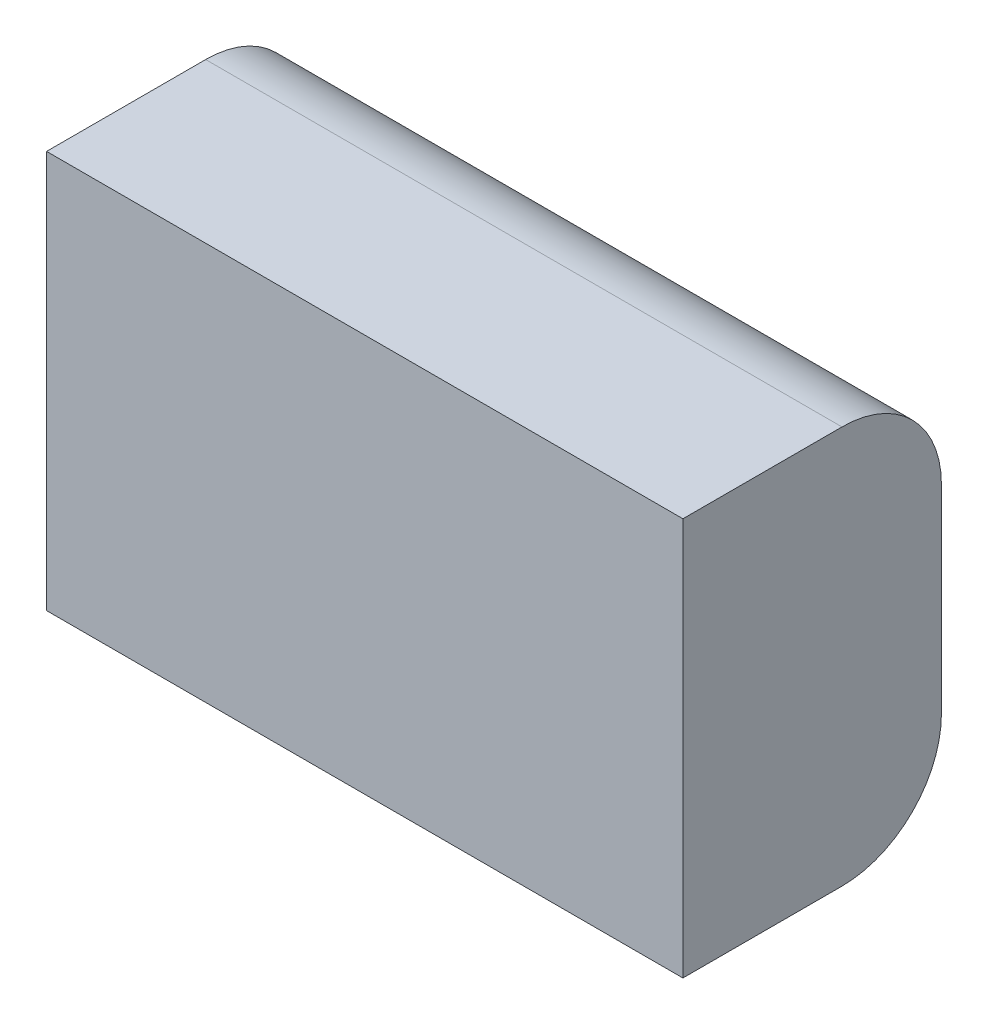
from build123d import *

# Parameters (mm, degrees)
BOSS_EXTRUDE1_DEPTH = 101.6


with BuildPart() as part:
    # Sketch1 → Boss-Extrude1 (new body, symmetric)
    with BuildSketch(Plane(origin=(0, 0, 0), x_dir=(0, 0, -1), z_dir=(1, 0, 0))):
        with BuildLine():
            Line((49.373646209, 66.02166065), (-1.426353791, 66.02166065))
            Line((-1.426353791, 66.02166065), (-1.426353791, -60.97833935))
            Line((-1.426353791, -60.97833935), (49.373646209, -60.97833935))
            ThreePointArc((49.373646209, -60.97833935), (71.824286512, -51.678979653), (81.123646209, -29.22833935))
            Line((81.123646209, -29.22833935), (81.123646209, 34.27166065))
            ThreePointArc((81.123646209, 34.27166065), (71.824286512, 56.722300952), (49.373646209, 66.02166065))
        make_face()
    extrude(amount=BOSS_EXTRUDE1_DEPTH, both=True)


solid = part.part
